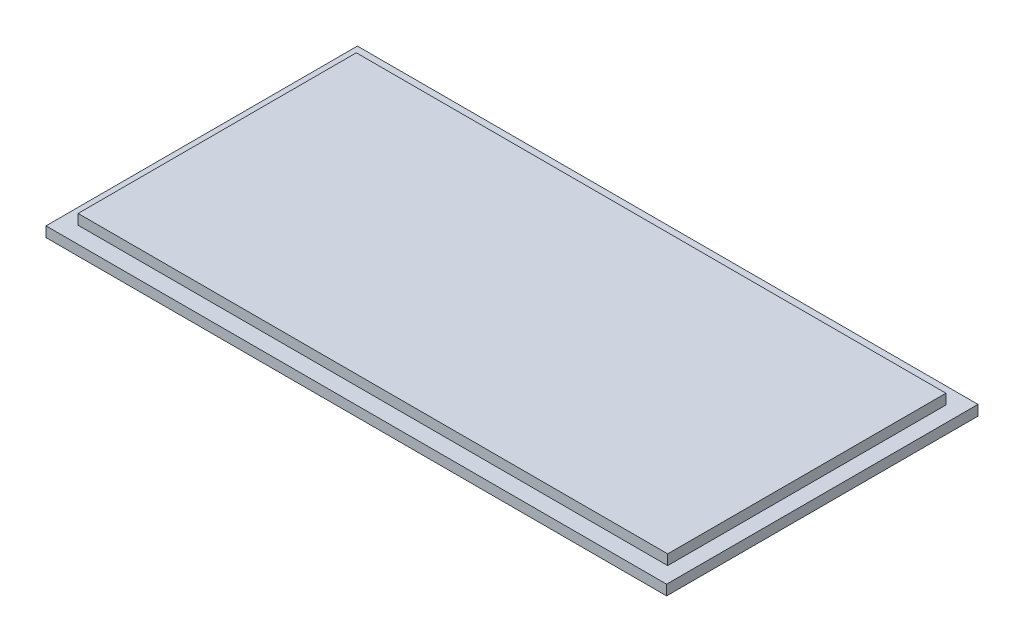
from build123d import *

# Parameters (mm, degrees)
SKETCH1_W           = 121.57
SKETCH1_H           = 61
BOSS_EXTRUDE1_DEPTH = 2
SKETCH2_W           = 115.5
SKETCH2_H           = 54.5
BOSS_EXTRUDE2_DEPTH = 2


with BuildPart() as part:
    # Sketch1 → Boss-Extrude1 (new body)
    with BuildSketch(Plane(origin=(0, 0, 0), x_dir=(1, 0, 0), z_dir=(0, 1, 0))):
        Rectangle(SKETCH1_W, SKETCH1_H)
    extrude(amount=BOSS_EXTRUDE1_DEPTH)

    # Sketch2 → Boss-Extrude2 (add)
    with BuildSketch(Plane(origin=(0, 2, 0), x_dir=(1, 0, 0), z_dir=(0, 1, 0))):
        Rectangle(SKETCH2_W, SKETCH2_H)
    extrude(amount=BOSS_EXTRUDE2_DEPTH)


solid = part.part
